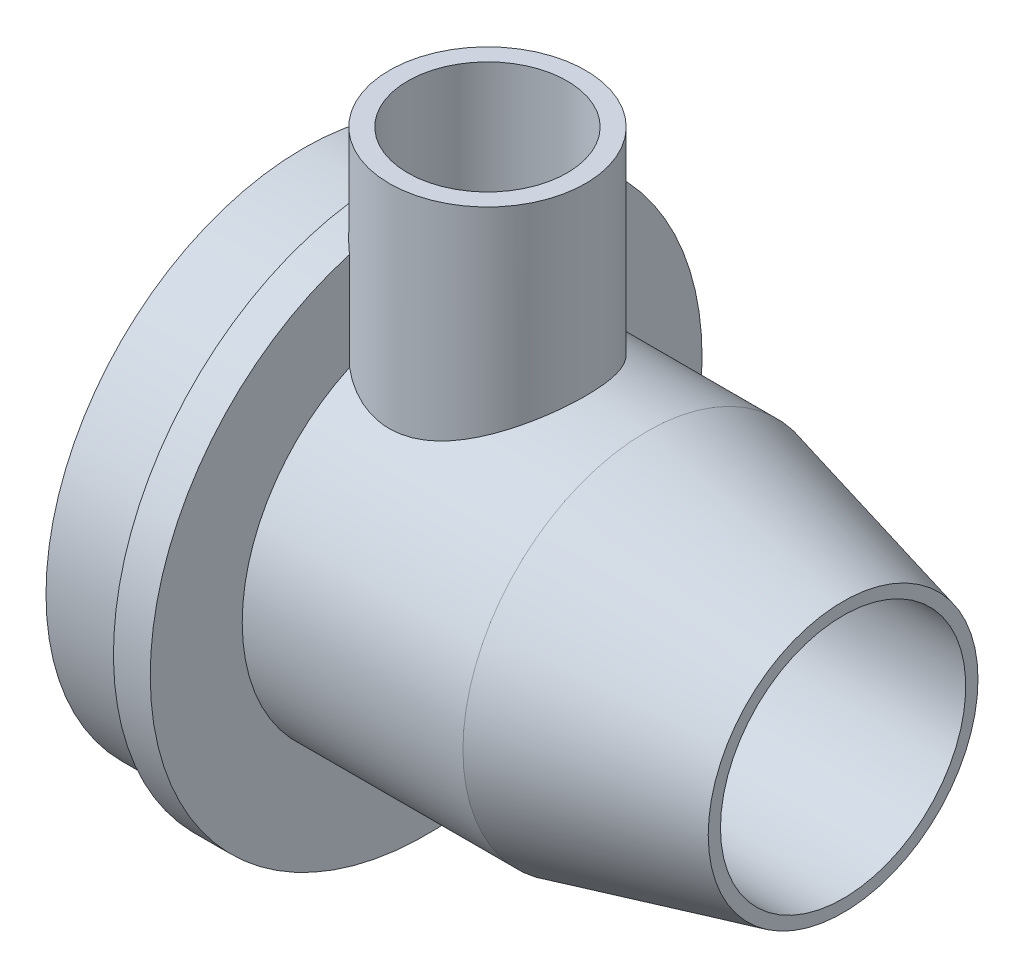
from build123d import *

# Parameters (mm, degrees)
BOSS_EXTRU_1_REACH           = 74.101
ESQUISSE2_R                  = 8
ENL_V_MAT_EXTRU_1_REACH      = 74.101
ENL_V_MAT_EXTRU_1_END_RADIUS = 10
ESQUISSE3_R                  = 6.5


with BuildPart() as part:
    # Esquisse1 → Révolution1 (revolve)
    with BuildSketch(Plane.XY, mode=Mode.PRIVATE) as r_volution1_sk:
        Polygon((44, 10), (0, 10), (0, 21), (7, 21), (7, 22.5), (10, 22.5), (10, 15), (28, 15), (44, 11), align=None)
    revolve(r_volution1_sk.sketch.rotate(Axis((0, 0, 0), (1, 0, 0)), 90), axis=Axis((0, 0, 0), (1, 0, 0)))

    # Esquisse2 → Boss.-Extru.1 (add, up to next)
    with BuildSketch(Plane(origin=(0, 30, 0), x_dir=(1, 0, 0), z_dir=(0, 1, 0)), mode=Mode.PRIVATE) as boss_extru_1_sk1:
        with Locations(Location((15, 0, 0), (0, 0, 270))):
            Circle(ESQUISSE2_R)
    boss_extru_1_tool1 = extrude(boss_extru_1_sk1.sketch, amount=-BOSS_EXTRU_1_REACH, mode=Mode.PRIVATE) - part.part
    add(boss_extru_1_tool1.solids().sort_by_distance((15, 30, 0))[0])

    # Enlèv. mat.-Extru.1: up to this cylinder (the profile starts outside it)
    enl_v_mat_extru_1_end = Plane(origin=(15, 0, 0), z_dir=(-1, 0, 0)) * Cylinder(ENL_V_MAT_EXTRU_1_END_RADIUS, 169.202, mode=Mode.PRIVATE)
    # Esquisse3 → Enlèv. mat.-Extru.1 (cut, up to the surface)
    with BuildSketch(Plane(origin=(0, 30, 0), x_dir=(1, 0, 0), z_dir=(0, 1, 0)), mode=Mode.PRIVATE) as enl_v_mat_extru_1_sk1:
        with Locations(Location((15, 0, 0), (0, 0, 270))):
            Circle(ESQUISSE3_R)
    enl_v_mat_extru_1_tool1 = extrude(enl_v_mat_extru_1_sk1.sketch, amount=-ENL_V_MAT_EXTRU_1_REACH, mode=Mode.PRIVATE) - enl_v_mat_extru_1_end
    add(enl_v_mat_extru_1_tool1.solids().sort_by_distance((15, 30, 0))[0], mode=Mode.SUBTRACT)


solid = part.part
